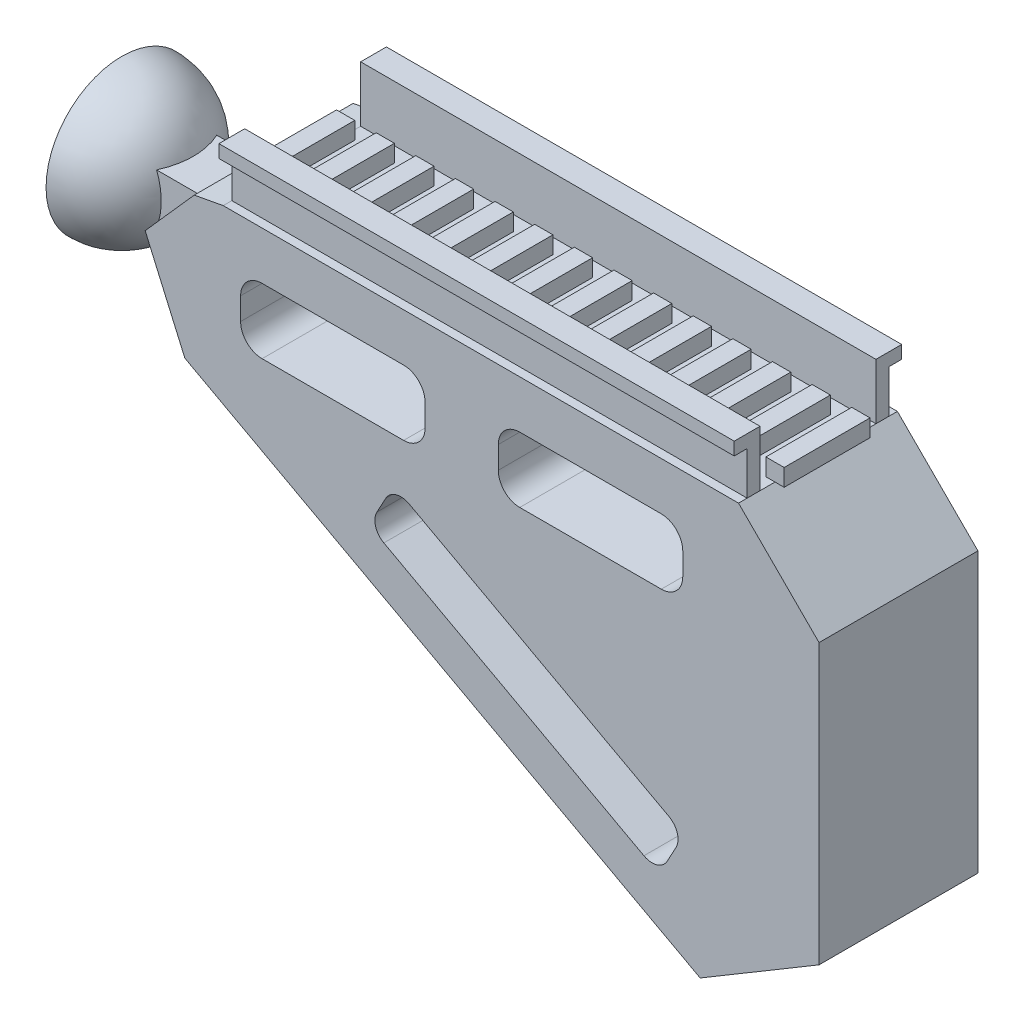
from build123d import *

# Parameters (mm, degrees)
BOSS_EXTRUDE1_DEPTH     = 37
CUT_EXTRUDE1_DEPTH      = 37
CUT_EXTRUDE1_DEPTH_BACK = 1
SKETCH13_W              = 4.25
SKETCH13_H              = 20
BOSS_EXTRUDE3_DEPTH     = 4
REVOLVE4_ANGLE          = 180
BOSS_EXTRUDE5_START     = 1.719088
SKETCH24_W              = 14
SKETCH24_H              = 12
BOSS_EXTRUDE5_DEPTH     = 13.336158
BOSS_EXTRUDE6_DEPTH     = 120
CUT_EXTRUDE2_DEPTH      = 37


with BuildPart() as part:
    # Sketch8 → Boss-Extrude1 (new body)
    with BuildSketch(Plane.XY):
        Polygon((0, 18.749877704), (-119.999774223, 18.749877704), (-126.751399414, 17.492106186), (-138.175152238, 4.606192282), (-128.930068484, -16.486854671), (-8.930236022, -81.486624843), (18.749877704, -64.999999997), (18.749877704, 0), align=None)
    extrude(amount=BOSS_EXTRUDE1_DEPTH)

    # Sketch10 → Cut-Extrude1 (cut, two sides)
    with BuildSketch(Plane.XY) as cut_extrude1_sk:
        with BuildLine():
            Line((-50.945075891, -7.596026142), (-17.985230256, -7.596026142))
            ThreePointArc((-17.985230256, -7.596026142), (-14.44969635, -6.131560048), (-12.985230256, -2.596026142))
            Line((-12.985230256, -2.596026142), (-12.985230256, 2.596026142))
            ThreePointArc((-12.985230256, 2.596026142), (-14.44969635, 6.131560048), (-17.985230256, 7.596026142))
            Line((-17.985230256, 7.596026142), (-50.945075891, 7.596026142))
            ThreePointArc((-50.945075891, 7.596026142), (-54.480609797, 6.131560048), (-55.945075891, 2.596026142))
            Line((-55.945075891, 2.596026142), (-55.945075891, -2.596026142))
            ThreePointArc((-55.945075891, -2.596026142), (-54.480609797, -6.131560048), (-50.945075891, -7.596026142))
        make_face()
        with BuildLine():
            Line((-110.945075891, 7.596026142), (-77.985230256, 7.596026142))
            ThreePointArc((-77.985230256, 7.596026142), (-74.44969635, 6.131560048), (-72.985230256, 2.596026142))
            Line((-72.985230256, 2.596026142), (-72.985230256, -2.596026142))
            ThreePointArc((-72.985230256, -2.596026142), (-74.44969635, -6.131560048), (-77.985230256, -7.596026142))
            Line((-77.985230256, -7.596026142), (-110.945075891, -7.596026142))
            ThreePointArc((-110.945075891, -7.596026142), (-114.480609797, -6.131560048), (-115.945075891, -2.596026142))
            Line((-115.945075891, -2.596026142), (-115.945075891, 2.596026142))
            ThreePointArc((-115.945075891, 2.596026142), (-114.480609797, 6.131560048), (-110.945075891, 7.596026142))
        make_face()
    extrude(amount=CUT_EXTRUDE1_DEPTH, mode=Mode.SUBTRACT)
    extrude(cut_extrude1_sk.sketch, amount=-CUT_EXTRUDE1_DEPTH_BACK, mode=Mode.SUBTRACT)

    # Sketch13 → Boss-Extrude3 (add)
    with BuildSketch(Plane(origin=(0, 18.749877704, 0), x_dir=(1, 0, 0), z_dir=(0, 1, 0))):
        with Locations((0, -18.5)):
            Rectangle(SKETCH13_W, SKETCH13_H)
        with Locations((-9.23, -18.5)):
            Rectangle(SKETCH13_W, SKETCH13_H)
        with Locations((-18.46, -18.5)):
            Rectangle(SKETCH13_W, SKETCH13_H)
        with Locations((-27.69, -18.5)):
            Rectangle(SKETCH13_W, SKETCH13_H)
        with Locations((-36.92, -18.5)):
            Rectangle(SKETCH13_W, SKETCH13_H)
        with Locations((-46.15, -18.5)):
            Rectangle(SKETCH13_W, SKETCH13_H)
        with Locations((-55.38, -18.5)):
            Rectangle(SKETCH13_W, SKETCH13_H)
        with Locations((-64.61, -18.5)):
            Rectangle(SKETCH13_W, SKETCH13_H)
        with Locations((-73.84, -18.5)):
            Rectangle(SKETCH13_W, SKETCH13_H)
        with Locations((-83.07, -18.5)):
            Rectangle(SKETCH13_W, SKETCH13_H)
        with Locations((-92.3, -18.5)):
            Rectangle(SKETCH13_W, SKETCH13_H)
        with Locations((-101.53, -18.5)):
            Rectangle(SKETCH13_W, SKETCH13_H)
        with Locations((-110.76, -18.5)):
            Rectangle(SKETCH13_W, SKETCH13_H)
        with Locations((-119.99, -18.5)):
            Rectangle(SKETCH13_W, SKETCH13_H)
    extrude(amount=BOSS_EXTRUDE3_DEPTH)



with BuildPart() as body_2:
    # Sketch23 → Revolve4 (revolve)
    with BuildSketch(Plane.ZY.offset(162.115)):
        with BuildLine():
            Line((18.502309671, 18.552772626), (18.502309671, 15.181416266))
            ThreePointArc((18.502309671, 15.181416266), (4.238878914, 0.917985509), (18.502309671, -13.345445248))
            Line((18.502309671, -13.345445248), (18.502309671, -16.716801609))
            ThreePointArc((18.502309671, -16.716801609), (0.867522554, 0.917985509), (18.502309671, 18.552772626))
        make_face()
    revolve(axis=Axis((-162.115, 19.719780597, 18.502309671), (0, -1, 0)), revolution_arc=REVOLVE4_ANGLE)


with BuildPart() as part_1:
    add(part.part)

    add(body_2.part)  # Boss-Extrude5 merges body 2
    # Sketch24 → Boss-Extrude5 (add)
    with BuildSketch(Plane.ZY.offset(132.115).offset(BOSS_EXTRUDE5_START)):
        with Locations((18.502309671, 0.701872922)):
            Rectangle(SKETCH24_W, SKETCH24_H)
    extrude(amount=BOSS_EXTRUDE5_DEPTH)

    # Sketch25 → Boss-Extrude6 (add)
    with BuildSketch(Plane(origin=(0, 0, 0), x_dir=(0, 0, -1), z_dir=(1, 0, 0))):
        Polygon((-32, 31.749877704), (-32, 18.749877704), (-35, 18.749877704), (-35, 28.749877704), (-38, 28.749877704), (-38, 31.749877704), align=None)
        Polygon((1, 31.749877704), (-5, 31.749877704), (-5, 18.749877704), (-2, 18.749877704), (-2, 28.749877704), (1, 28.749877704), align=None)
    extrude(amount=-BOSS_EXTRUDE6_DEPTH)

    # Sketch26 → Cut-Extrude2 (cut)
    with BuildSketch(Plane.XY):
        with BuildLine():
            Line((-82.157166646, -21.371866468), (-84.205180797, -25.15282376))
            ThreePointArc((-84.205180797, -25.15282376), (-84.522155627, -28.19783771), (-82.593140666, -30.575122775))
            Line((-82.593140666, -30.575122775), (-22.030526844, -63.379801738))
            ThreePointArc((-22.030526844, -63.379801738), (-18.985512893, -63.696776568), (-16.608227828, -61.767761607))
            Line((-16.608227828, -61.767761607), (-14.560213677, -57.986804316))
            ThreePointArc((-14.560213677, -57.986804316), (-14.243238847, -54.941790365), (-16.172253808, -52.5645053))
            Line((-16.172253808, -52.5645053), (-76.73486763, -19.759826338))
            ThreePointArc((-76.73486763, -19.759826338), (-79.779881581, -19.442851507), (-82.157166646, -21.371866468))
        make_face()
    extrude(amount=CUT_EXTRUDE2_DEPTH, mode=Mode.SUBTRACT)

    # Sketch27 → Revolve-Thin1 (revolve)
    with BuildSketch(Plane.XY.offset(18.5)):
        Polygon((-83.181173721, -23.262345114), (-15.584220753, -59.877282961), (-13.67909131, -56.360113388), (-81.276044279, -19.745175541), align=None)
    revolve(axis=Axis((-83.181173721, -23.262345114, 18.5), (0.879292393, -0.476282361, 0)))


solid = part_1.part
